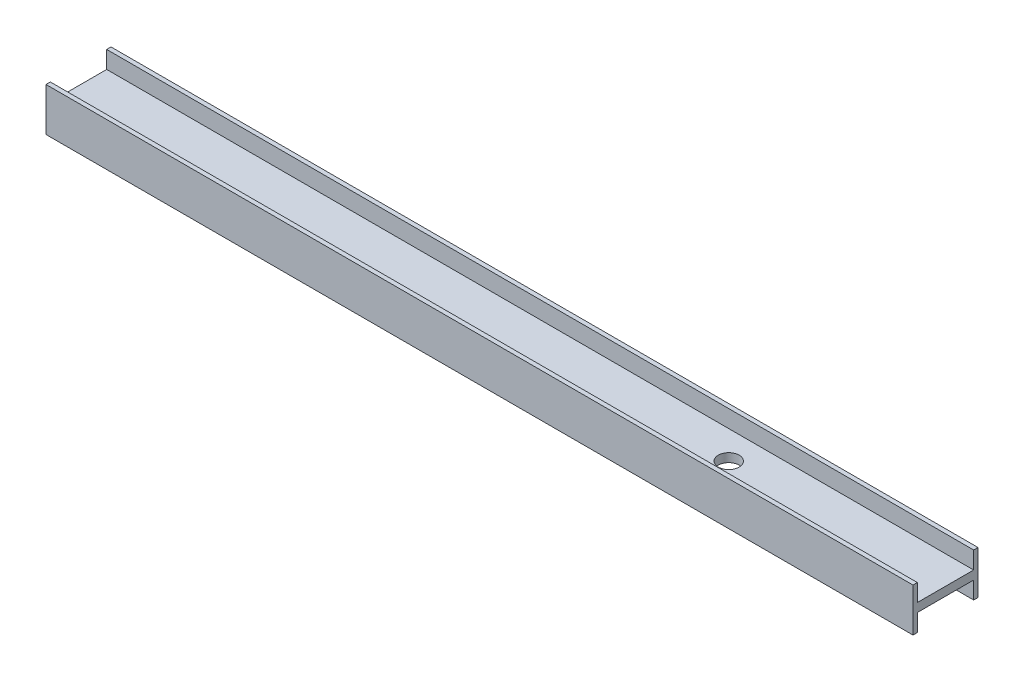
from build123d import *

# Parameters (mm, degrees)
SKETCH1_W           = 200
SKETCH1_H           = 15
BOSS_EXTRUDE1_DEPTH = 10
CUT_EXTRUDE1_DEPTH  = 4
SKETCH4_W           = 200
SKETCH4_H           = 13
CUT_EXTRUDE2_DEPTH  = 4
SKETCH5_R           = 2.4
CUT_EXTRUDE3_DEPTH  = 10


with BuildPart() as part:
    # Sketch1 → Boss-Extrude1 (new body)
    with BuildSketch(Plane(origin=(0, 0, 0), x_dir=(1, 0, 0), z_dir=(0, 1, 0))):
        with Locations((22.463138005, -9.901926804)):
            Rectangle(SKETCH1_W, SKETCH1_H)
    extrude(amount=BOSS_EXTRUDE1_DEPTH)

    # Sketch3 → Cut-Extrude1 (cut)
    with BuildSketch(Plane(origin=(0, 10, 0), x_dir=(1, 0, 0), z_dir=(0, 1, 0))):
        Polygon((-77.536861995, -3.454668646), (-77.536861995, -16.401926804), (122.463138005, -16.401926804), (122.463138005, -3.541728885), (122.463138005, -3.401926804), (-77.536861995, -3.401926804), align=None)
    extrude(amount=-CUT_EXTRUDE1_DEPTH, mode=Mode.SUBTRACT)

    # Sketch4 → Cut-Extrude2 (cut)
    with BuildSketch(Plane.XZ):
        with Locations((22.463138005, 9.901926804)):
            Rectangle(SKETCH4_W, SKETCH4_H)
    extrude(amount=-CUT_EXTRUDE2_DEPTH, mode=Mode.SUBTRACT)

    # Sketch5 → Cut-Extrude3 (cut)
    with BuildSketch(Plane(origin=(0, 4, 0), x_dir=(-1, 0, 0), z_dir=(0, -1, 0))):
        with Locations((-72.463138005, -9.901926804)):
            Circle(SKETCH5_R)
    extrude(amount=-CUT_EXTRUDE3_DEPTH, mode=Mode.SUBTRACT)


solid = part.part
